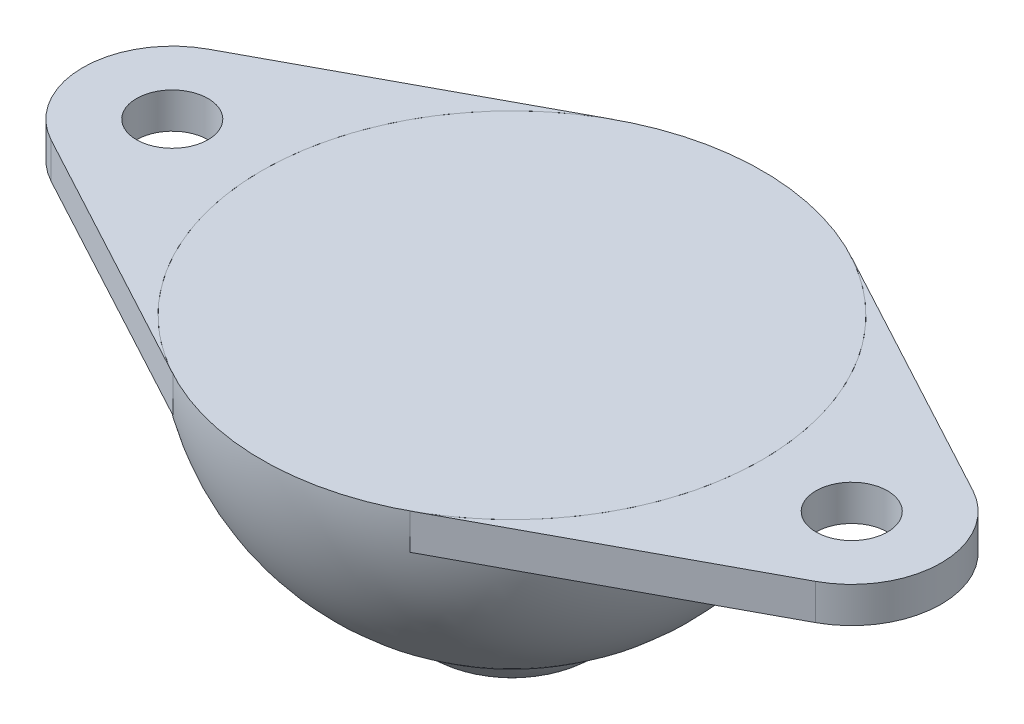
from build123d import *

# Parameters (mm, degrees)
SKETCH2_R           = 5
SKETCH2_R_2         = 2
BOSS_EXTRUDE1_DEPTH = 2


with BuildPart() as part:
    # Sketch1 → Revolve1 (revolve)
    with BuildSketch(Plane.XY):
        with BuildLine():
            Line((0, 9), (14, 9))
            ThreePointArc((14, 9), (12.129558808, 2.009019874), (7.018028125, -3.113929224))
            Line((7.018028125, -3.113929224), (7.018028125, 0))
            Line((7.018028125, 0), (7, 0))
            ThreePointArc((7, 0), (4.949747468, -4.949747468), (0, -7))
            Line((0, -7), (0, 9))
        make_face()
    revolve(axis=Axis((0, 9, 0), (0, -1, 0)))


with BuildPart() as body_2:
    # Sketch2 → Boss-Extrude1 (new body)
    with BuildSketch(Plane(origin=(0, 9, 0), x_dir=(1, 0, 0), z_dir=(0, 1, 0))):
        with BuildLine():
            Line((21.368421053, 4.403473824), (6.631578947, 12.329726707))
            ThreePointArc((6.631578947, 12.329726707), (12.017531054, 7.181848465), (14, 0))
            ThreePointArc((14, 0), (16.43505412, 4.291975376), (21.368421053, 4.403473824))
        make_face()
        with BuildLine():
            ThreePointArc((21.368421053, -4.403473824), (16.43505412, -4.291975376), (14, 0))
            ThreePointArc((14, 0), (12.017531054, -7.181848465), (6.631578947, -12.329726707))
            Line((6.631578947, -12.329726707), (21.368421053, -4.403473824))
        make_face()
        with Locations((19, 0)):
            Circle(SKETCH2_R)
        with Locations((19, 0)):
            Circle(SKETCH2_R_2, mode=Mode.SUBTRACT)
        with BuildLine():
            ThreePointArc((-6.631578947, -12.329726707), (-12.017531054, -7.181848465), (-14, 0))
            ThreePointArc((-14, 0), (-16.43505412, -4.291975376), (-21.368421053, -4.403473824))
            Line((-21.368421053, -4.403473824), (-6.631578947, -12.329726707))
        make_face()
        with BuildLine():
            Line((-6.631578947, 12.329726707), (-21.368421053, 4.403473824))
            ThreePointArc((-21.368421053, 4.403473824), (-16.43505412, 4.291975376), (-14, 0))
            ThreePointArc((-14, 0), (-12.017531054, 7.181848465), (-6.631578947, 12.329726707))
        make_face()
        with Locations((-19, 0)):
            Circle(SKETCH2_R)
        with Locations((-19, 0)):
            Circle(SKETCH2_R_2, mode=Mode.SUBTRACT)
    extrude(amount=-BOSS_EXTRUDE1_DEPTH)


solid = Compound([part.part, body_2.part])
